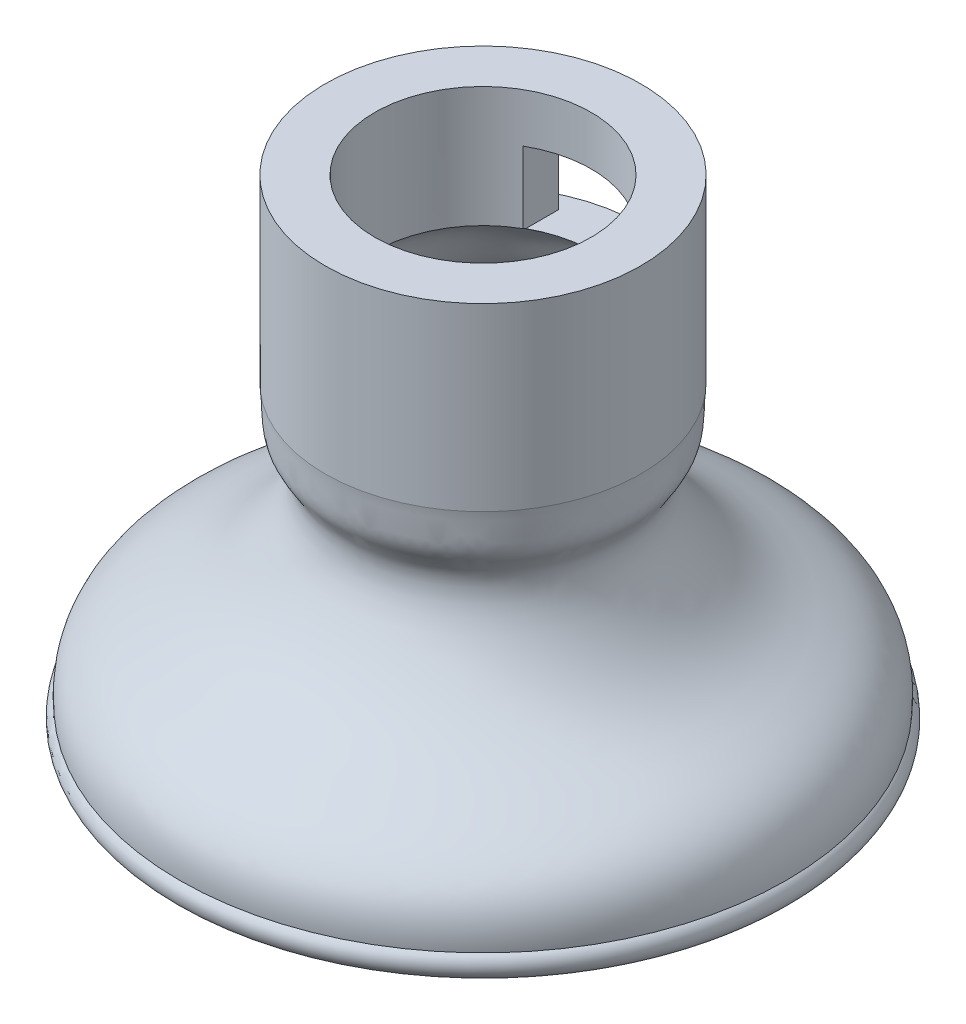
from build123d import *

# Parameters (mm, degrees)
ESBO_O2_W                  = 8.52075949
ESBO_O2_H                  = 5.764043184
CORTE_EXTRUS_O1_DEPTH      = 21
ESBO_O3_W                  = 2.250213953
ESBO_O3_H                  = 5.764043184
CORTE_EXTRUS_O2_DEPTH      = 21
CORTE_EXTRUS_O2_DEPTH_BACK = 21


with BuildPart() as part:
    # Esboço1 → Revolução1 (revolve)
    with BuildSketch(Plane.XY):
        with BuildLine():
            Line((12.5, 41.646579704), (12.5, 41.506128196))
            add(Edge.make_bspline(
                [(12.5, 41.506128196), (12.338389384, 40.134837747), (12.601764107, 38.305152117), (10.065188923, 35.645635864), (12.500651196, 30.458331587), (16.843058411, 26.670735), (22.76228445, 24.532888043), (24.224821104, 21.349310821), (24.046845434, 19.403944973)],
                knots=[0, 0, 0, 0, 0.101004703, 0.175039834, 0.372875088, 0.603292123, 0.835962091, 1, 1, 1, 1], degree=3))
            ThreePointArc((24.046845434, 19.403944973), (23.264534568, 17.438582109), (22.851836049, 19.513272788))
            add(Edge.make_bspline(
                [(11.308247772, 41.646579704), (11.281760283, 41.421829367), (11.241283492, 40.953310705), (11.207087563, 40.153140867), (11.188443128, 39.325301199), (11.101187915, 38.800994205), (10.999161677, 38.542871248), (10.84650313, 38.269361286), (10.628860527, 37.942340116), (10.368935554, 37.554835556), (10.092298736, 37.083824404), (9.789160953, 36.330082669), (9.651283083, 35.387021367), (9.788883574, 33.919158958), (10.43159292, 32.226529482), (11.534582968, 30.432466838), (12.730902254, 28.915450827), (14.063189235, 27.612944764), (15.516577401, 26.511762273), (17.117458176, 25.575765094), (18.736981448, 24.783206109), (20.230956508, 24.009113027), (21.467011577, 23.176371047), (22.186355151, 22.407246301), (22.575507066, 21.708478748), (22.780108979, 21.111549356), (22.870075885, 20.516676656), (22.88284487, 19.974221941), (22.865553692, 19.663213697), (22.851836049, 19.513272788)],
                knots=[0, 0, 0, 0, 0.015625, 0.03125, 0.0625, 0.09375, 0.109375, 0.125, 0.140625, 0.15625, 0.171875, 0.1875, 0.21875, 0.25, 0.3125, 0.375, 0.4375, 0.5, 0.5625, 0.625, 0.6875, 0.75, 0.8125, 0.875, 0.90625, 0.9375, 0.96875, 0.984375, 1, 1, 1, 1], degree=3))
            add(Edge.make_bspline(
                [(11.308247772, 41.646579704), (10.488228177, 43.241261294), (10.332658745, 45.295831645), (8.575926678, 46.236967031)],
                knots=[0, 0, 0, 0, 1, 1, 1, 1], degree=3))
            Line((8.575926678, 46.236967031), (8.575926678, 55.780385677))
            Line((8.575926678, 55.780385677), (12.5, 55.780385677))
            Line((12.5, 55.780385677), (12.5, 46.236967031))
            Line((12.5, 46.236967031), (12.5, 41.646579704))
        make_face()
    revolve(axis=Axis((0, 44.517371893, 0), (0, -1, 0)))

    # Esboço2 → Corte-extrusão1 (cut)
    with BuildSketch(Plane.XY):
        with Locations((0, 49.017313479)):
            Rectangle(ESBO_O2_W, ESBO_O2_H)
    extrude(amount=-CORTE_EXTRUS_O1_DEPTH, mode=Mode.SUBTRACT)

    # Esboço3 → Corte-extrusão2 (cut, two sides)
    with BuildSketch(Plane(origin=(0, 0, 0), x_dir=(0, 0, -1), z_dir=(1, 0, 0))) as corte_extrus_o2_sk:
        with Locations((11.374893024, 49.017313479)):
            Rectangle(ESBO_O3_W, ESBO_O3_H)
    extrude(amount=CORTE_EXTRUS_O2_DEPTH, mode=Mode.SUBTRACT)
    extrude(corte_extrus_o2_sk.sketch, amount=-CORTE_EXTRUS_O2_DEPTH_BACK, mode=Mode.SUBTRACT)


solid = part.part
